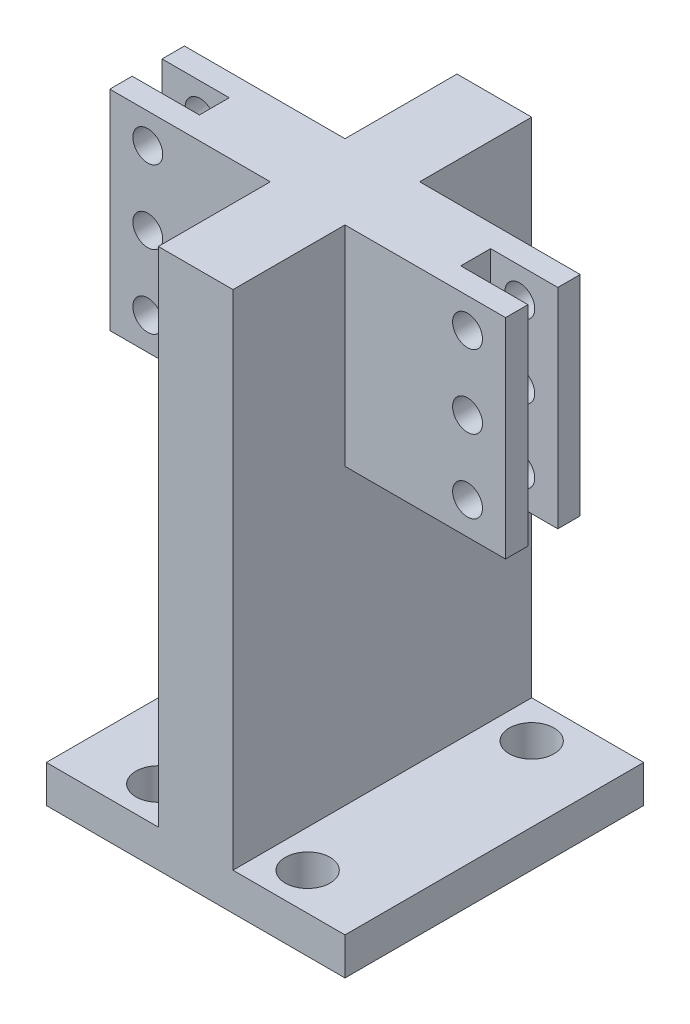
from build123d import *

# Parameters (mm, degrees)
SKETCH_1_W          = 40
SKETCH_1_H          = 40
SKETCH_1_R          = 3
EXTRUDE_1_DEPTH     = 5
SKETCH_2_W          = 10
SKETCH_2_H          = 40
EXTRUDE_2_DEPTH     = 67.34
SKETCH_3_W          = 10
SKETCH_3_H          = 28
EXTRUDE_3_DEPTH     = 24.5
SKETCH_5_R          = 2
CUT_EXTRUDE_1_DEPTH = 12.25
SKETCH_6_W          = 12
SKETCH_6_H          = 28
CUT_EXTRUDE_2_DEPTH = 2
SKETCH_7_W          = 3
SKETCH_7_H          = 28
CUT_EXTRUDE_3_DEPTH = 25


with BuildPart() as part:
    # 草图1 → 凸台-拉伸1 (new body)
    with BuildSketch(Plane(origin=(0, 0, 0), x_dir=(1, 0, 0), z_dir=(0, 1, 0))):
        Rectangle(SKETCH_1_W, SKETCH_1_H)
        with Locations((-10, -15)):
            Circle(SKETCH_1_R, mode=Mode.SUBTRACT)
        with Locations((10, -15)):
            Circle(SKETCH_1_R, mode=Mode.SUBTRACT)
        with Locations((10, 15)):
            Circle(SKETCH_1_R, mode=Mode.SUBTRACT)
        with Locations((-10, 15)):
            Circle(SKETCH_1_R, mode=Mode.SUBTRACT)
    extrude(amount=EXTRUDE_1_DEPTH)

    # 草图2 → 凸台-拉伸2 (add)
    with BuildSketch(Plane(origin=(0, 5, 0), x_dir=(1, 0, 0), z_dir=(0, 1, 0))):
        Rectangle(SKETCH_2_W, SKETCH_2_H)
    extrude(amount=EXTRUDE_2_DEPTH)

    # 草图3 → 凸台-拉伸3 (add)
    with BuildSketch(Plane.ZY.offset(5)):
        with Locations((0, 58.34)):
            Rectangle(SKETCH_3_W, SKETCH_3_H)
    extrude_3 = extrude(amount=EXTRUDE_3_DEPTH)

    # 草图5 → 切除-拉伸1 (cut, symmetric)
    with BuildSketch(Plane.XY):
        with Locations((-21.41, 68.31)):
            Circle(SKETCH_5_R)
        with Locations((-21.41, 58.49)):
            Circle(SKETCH_5_R)
        with Locations((-21.41, 48.67)):
            Circle(SKETCH_5_R)
    cut_extrude_1 = extrude(amount=CUT_EXTRUDE_1_DEPTH, both=True, mode=Mode.SUBTRACT)

    # 草图6 → 切除-拉伸2 (cut, symmetric)
    with BuildSketch(Plane.XY):
        with Locations((-23.5, 58.34)):
            Rectangle(SKETCH_6_W, SKETCH_6_H)
    cut_extrude_2 = extrude(amount=CUT_EXTRUDE_2_DEPTH, both=True, mode=Mode.SUBTRACT)

    # 镜向1: 凸台-拉伸3, 切除-拉伸1, 切除-拉伸2 across plane
    add(extrude_3.mirror(Plane(origin=(0, 0, 0), x_dir=(0, 0, 1), z_dir=(1, 0, 0))))
    add(cut_extrude_1.mirror(Plane(origin=(0, 0, 0), x_dir=(0, 0, 1), z_dir=(1, 0, 0))), mode=Mode.SUBTRACT)
    add(cut_extrude_2.mirror(Plane(origin=(0, 0, 0), x_dir=(0, 0, 1), z_dir=(1, 0, 0))), mode=Mode.SUBTRACT)

    # 草图7 → 切除-拉伸3 (cut, symmetric)
    with BuildSketch(Plane.XY):
        with Locations((-28, 58.34)):
            Rectangle(SKETCH_7_W, SKETCH_7_H)
    cut_extrude_3 = extrude(amount=CUT_EXTRUDE_3_DEPTH, both=True, mode=Mode.SUBTRACT)

    # 镜向2: 切除-拉伸3 across plane
    add(cut_extrude_3.mirror(Plane(origin=(0, 0, 0), x_dir=(0, 0, 1), z_dir=(1, 0, 0))), mode=Mode.SUBTRACT)


solid = part.part
